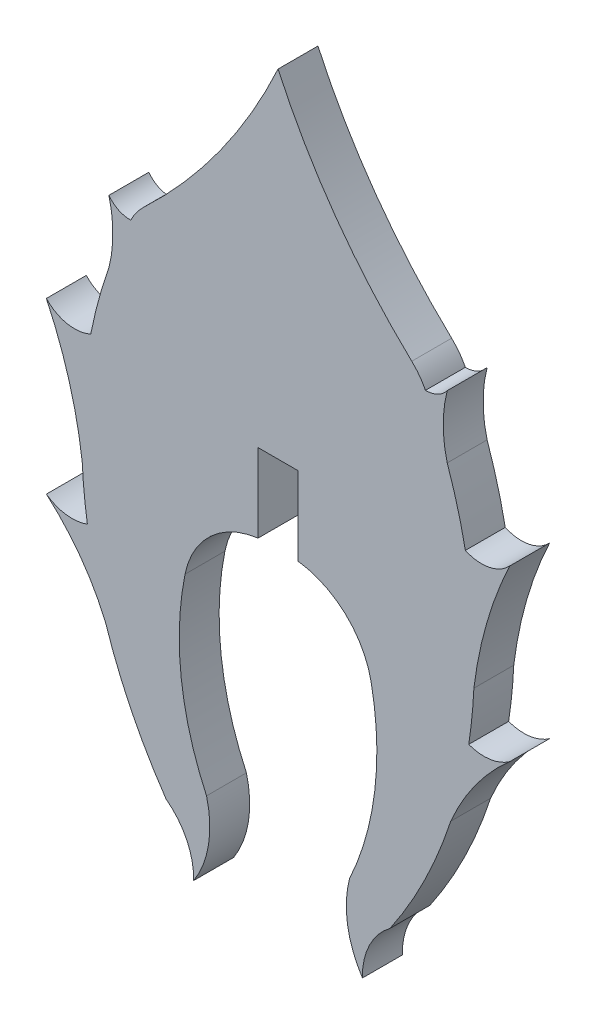
from build123d import *

# Parameters (mm, degrees)
BOSS_EXTRUDE2_DEPTH = 1.524


with BuildPart() as part:
    # Sketch1 → Boss-Extrude2 (new body)
    with BuildSketch(Plane.XY):
        with BuildLine():
            Line((-0.765410013, -0.503143286), (-0.764991894, 2.492240818))
            Line((-0.764991894, 2.492240818), (0.760988125, 2.492240818))
            Line((0.760988125, 2.492240818), (0.760988125, -0.503092163))
            ThreePointArc((0.760988125, -0.503092163), (2.573737831, -1.346888202), (3.55195433, -3.090776309))
            ThreePointArc((3.55195433, -3.090776309), (3.695640119, -6.618686281), (2.730705837, -10.015110313))
            ThreePointArc((2.730705837, -10.015110313), (2.653965632, -11.591332876), (3.221955388, -13.063662413))
            ThreePointArc((3.221955388, -13.063662413), (3.485746852, -11.851447246), (4.275671769, -10.894854243))
            ThreePointArc((4.275671769, -10.894854243), (5.603621463, -8.626073328), (6.594544537, -6.191142388))
            ThreePointArc((6.594544537, -6.191142388), (7.545888132, -4.512710917), (8.849839361, -3.090776309))
            ThreePointArc((8.849839361, -3.090776309), (8.093123436, -3.392493185), (7.283276893, -3.30417195))
            ThreePointArc((7.283276893, -3.30417195), (7.407565604, -2.328155091), (7.47948144, -1.346888202))
            ThreePointArc((7.47948144, -1.346888202), (7.974772805, 1.073186615), (8.849839361, 3.383237301))
            ThreePointArc((8.849839361, 3.383237301), (8.055674116, 2.944556231), (7.154590571, 3.050329405))
            ThreePointArc((7.154590571, 3.050329405), (6.853539824, 4.337001735), (6.46088015, 5.598736896))
            ThreePointArc((6.46088015, 5.598736896), (6.307858777, 6.794433229), (6.46088015, 7.990129562))
            ThreePointArc((6.46088015, 7.990129562), (6.094168188, 7.687528271), (5.630106714, 7.584125409))
            ThreePointArc((5.630106714, 7.584125409), (5.398611626, 7.957700377), (5.106185913, 8.285778776))
            ThreePointArc((5.106185913, 8.285778776), (2.209855231, 11.5967516), (-0.002002475, 15.39924525))
            ThreePointArc((-0.002002475, 15.39924525), (-2.213860181, 11.5967516), (-5.110190864, 8.285778776))
            ThreePointArc((-5.110190864, 8.285778776), (-5.402616576, 7.957700377), (-5.634111665, 7.584125409))
            ThreePointArc((-5.634111665, 7.584125409), (-6.098173139, 7.687528271), (-6.4648851, 7.990129562))
            ThreePointArc((-6.4648851, 7.990129562), (-6.311863727, 6.794433229), (-6.4648851, 5.598736896))
            ThreePointArc((-6.4648851, 5.598736896), (-6.857544775, 4.337001735), (-7.158595522, 3.050329405))
            ThreePointArc((-7.158595522, 3.050329405), (-8.059679066, 2.944556231), (-8.853844312, 3.383237301))
            ThreePointArc((-8.853844312, 3.383237301), (-7.978777755, 1.073186615), (-7.48348639, -1.346888202))
            ThreePointArc((-7.48348639, -1.346888202), (-7.411570554, -2.328155091), (-7.287281843, -3.30417195))
            ThreePointArc((-7.287281843, -3.30417195), (-8.097128387, -3.392493185), (-8.853844312, -3.090776309))
            ThreePointArc((-8.853844312, -3.090776309), (-7.549893082, -4.512710917), (-6.598549488, -6.191142388))
            ThreePointArc((-6.598549488, -6.191142388), (-5.607626413, -8.626073328), (-4.27967672, -10.894854243))
            ThreePointArc((-4.27967672, -10.894854243), (-3.489751802, -11.851447246), (-3.225960338, -13.063662413))
            ThreePointArc((-3.225960338, -13.063662413), (-2.657970582, -11.591332876), (-2.734710788, -10.015110313))
            ThreePointArc((-2.734710788, -10.015110313), (-3.69964507, -6.618686281), (-3.555959281, -3.090776309))
            ThreePointArc((-3.555959281, -3.090776309), (-2.577896844, -1.347030777), (-0.765410013, -0.503143286))
        make_face()
    extrude(amount=BOSS_EXTRUDE2_DEPTH)


solid = part.part
